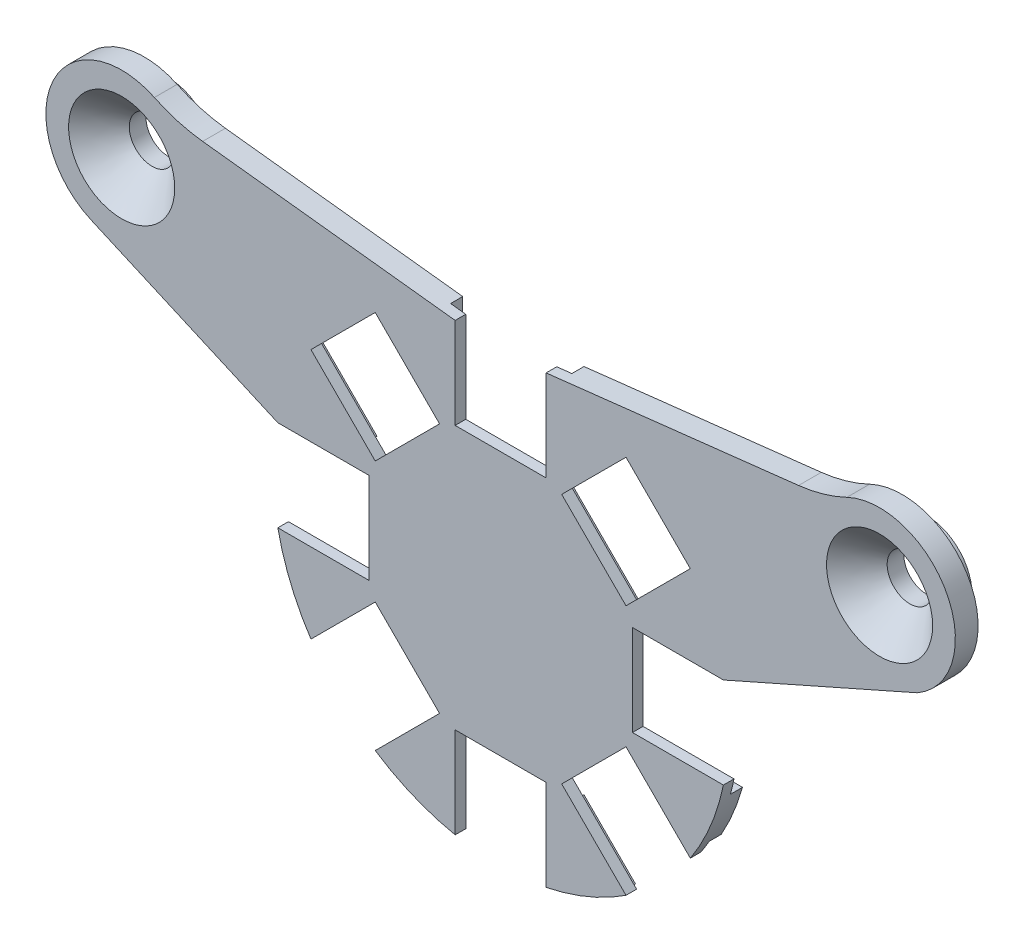
from build123d import *

# Parameters (mm, degrees)
SKETCH_1_R          = 1.5
EXTRUDE_1_DEPTH     = 1.5
CUT_EXTRUDE_2_DEPTH = 0.8
SKETCH_4_R          = 3
SKETCH_4_R_2        = 1.5
EXTRUDE_2_DEPTH     = 1.6
FILLET_1_R          = 1
CHAMFER_1_SIZE      = 2


with BuildPart() as part:
    # Эскиз1 → Бобышка-Вытянуть1 (new body)
    with BuildSketch(Plane.XY):
        with BuildLine():
            Line((-3, 14.696938457), (-3, 8.696938457))
            Line((-3, 8.696938457), (3, 8.696938457))
            Line((3, 8.696938457), (3, 14.696938457))
            Line((3, 14.696938457), (19.657078674, 16.594796577))
            ThreePointArc((19.657078674, 16.594796577), (21.287556094, 16.919662188), (22.841677521, 17.51017118))
            ThreePointArc((22.841677521, 17.51017118), (29.425159504, 15.327651899), (27.493638863, 8.666206601))
            Line((27.493638863, 8.666206601), (14.696938457, 3))
            Line((14.696938457, 3), (8.696938457, 3))
            Line((8.696938457, 3), (8.696938457, -3))
            Line((8.696938457, -3), (14.696938457, -3))
            ThreePointArc((14.696938457, -3), (13.858192988, -5.740251485), (12.513625189, -8.270984502))
            Line((12.513625189, -8.270984502), (8.270984502, -4.028343815))
            Line((8.270984502, -4.028343815), (4.028343815, -8.270984502))
            Line((4.028343815, -8.270984502), (8.270984502, -12.513625189))
            ThreePointArc((8.270984502, -12.513625189), (5.740251485, -13.858192988), (3, -14.696938457))
            Line((3, -14.696938457), (3, -8.696938457))
            Line((3, -8.696938457), (-3, -8.696938457))
            Line((-3, -8.696938457), (-3, -14.696938457))
            ThreePointArc((-3, -14.696938457), (-5.740251485, -13.858192988), (-8.270984502, -12.513625189))
            Line((-8.270984502, -12.513625189), (-4.028343815, -8.270984502))
            Line((-4.028343815, -8.270984502), (-8.270984502, -4.028343815))
            Line((-8.270984502, -4.028343815), (-12.513625189, -8.270984502))
            ThreePointArc((-12.513625189, -8.270984502), (-13.858192988, -5.740251485), (-14.696938457, -3))
            Line((-14.696938457, -3), (-8.696938457, -3))
            Line((-8.696938457, -3), (-8.696938457, 3))
            Line((-8.696938457, 3), (-14.696938457, 3))
            Line((-14.696938457, 3), (-27.014954435, 8.423980045))
            ThreePointArc((-27.014954435, 8.423980045), (-29.543661072, 15.086898192), (-22.841677521, 17.51017118))
            ThreePointArc((-22.841677521, 17.51017118), (-21.287556094, 16.919662188), (-19.657078674, 16.594796577))
            Line((-19.657078674, 16.594796577), (-3, 14.696938457))
        make_face()
        with Locations((-25, 13)):
            Circle(SKETCH_1_R, mode=Mode.SUBTRACT)
        with Locations((25, 13)):
            Circle(SKETCH_1_R, mode=Mode.SUBTRACT)
        Polygon((4.028343815, 8.270984502), (8.270984502, 4.028343815), (12.513625189, 8.270984502), (8.270984502, 12.513625189), align=None, mode=Mode.SUBTRACT)
        Polygon((-8.270984502, 4.028343815), (-4.028343815, 8.270984502), (-8.270984502, 12.513625189), (-12.513625189, 8.270984502), align=None, mode=Mode.SUBTRACT)
    extrude(amount=EXTRUDE_1_DEPTH)

    # Эскиз3 → Вырез-Вытянуть2 (cut)
    with BuildSketch(Plane(origin=(0, 0, 0), x_dir=(-1, 0, 0), z_dir=(0, 0, -1))):
        Polygon((-4, 7.696938457), (-4, 9.656854249), (-7.87527044, 13.53212469), (-13.53212469, 7.87527044), (-9.656854249, 4), (-7.696938457, 4), (-7.696938457, 3.188176298), (-3.188176298, 7.696938457), align=None)
        Polygon((-8.270984502, 4.028343815), (-12.513625189, 8.270984502), (-8.270984502, 12.513625189), (-4.028343815, 8.270984502), align=None, mode=Mode.SUBTRACT)
        Polygon((-2.614130252, 8.270984502), (-4, 9.656854249), (-4, 7.696938457), (-3.188176298, 7.696938457), align=None)
        Polygon((-3, 14.696938457), (-4, 14.81087549), (-4, 9.656854249), (-2.614130252, 8.270984502), (-3.188176298, 7.696938457), (3.188176298, 7.696938457), (2.614130252, 8.270984502), (4, 9.656854249), (4, 14.81087549), (3, 14.696938457), (3, 8.696938457), (-3, 8.696938457), align=None)
        Polygon((4, 7.696938457), (4, 9.656854249), (2.614130252, 8.270984502), (3.188176298, 7.696938457), align=None)
        Polygon((7.87527044, 13.53212469), (4, 9.656854249), (4, 7.696938457), (3.188176298, 7.696938457), (7.696938457, 3.188176298), (7.696938457, 4), (9.656854249, 4), (13.53212469, 7.87527044), align=None)
        Polygon((4.028343815, 8.270984502), (8.270984502, 12.513625189), (12.513625189, 8.270984502), (8.270984502, 4.028343815), align=None, mode=Mode.SUBTRACT)
        Polygon((7.696938457, 4), (7.696938457, 3.188176298), (8.270984502, 2.614130252), (9.656854249, 4), align=None)
        with BuildLine():
            Line((8.270984502, 2.614130252), (7.696938457, 3.188176298))
            Line((7.696938457, 3.188176298), (7.696938457, -3.188176298))
            Line((7.696938457, -3.188176298), (8.270984502, -2.614130252))
            Line((8.270984502, -2.614130252), (9.656854249, -4))
            Line((9.656854249, -4), (14.456832295, -4))
            ThreePointArc((14.456832295, -4), (14.585458075, -3.502058358), (14.696938457, -3))
            Line((14.696938457, -3), (8.696938457, -3))
            Line((8.696938457, -3), (8.696938457, 3))
            Line((8.696938457, 3), (14.696938457, 3))
            Line((14.696938457, 3), (15.137314264, 3.193910253))
            Line((15.137314264, 3.193910253), (15.137314264, 4))
            Line((15.137314264, 4), (9.656854249, 4))
            Line((9.656854249, 4), (8.270984502, 2.614130252))
        make_face()
        Polygon((8.270984502, -2.614130252), (7.696938457, -3.188176298), (7.696938457, -4), (9.656854249, -4), align=None)
        with BuildLine():
            Line((7.696938457, -4), (7.696938457, -3.188176298))
            Line((7.696938457, -3.188176298), (3.188176298, -7.696938457))
            Line((3.188176298, -7.696938457), (4, -7.696938457))
            Line((4, -7.696938457), (4, -9.656854249))
            Line((4, -9.656854249), (7.394097025, -13.050951275))
            ThreePointArc((7.394097025, -13.050951275), (7.837147099, -12.789805525), (8.270984502, -12.513625189))
            Line((8.270984502, -12.513625189), (4.028343815, -8.270984502))
            Line((4.028343815, -8.270984502), (8.270984502, -4.028343815))
            Line((8.270984502, -4.028343815), (12.513625189, -8.270984502))
            ThreePointArc((12.513625189, -8.270984502), (12.789805525, -7.837147099), (13.050951275, -7.394097025))
            Line((13.050951275, -7.394097025), (9.656854249, -4))
            Line((9.656854249, -4), (7.696938457, -4))
        make_face()
        with BuildLine():
            Line((3.188176298, -7.696938457), (-3.188176298, -7.696938457))
            Line((-3.188176298, -7.696938457), (-2.614130252, -8.270984502))
            Line((-2.614130252, -8.270984502), (-4, -9.656854249))
            Line((-4, -9.656854249), (-4, -14.456832295))
            ThreePointArc((-4, -14.456832295), (-3.502058358, -14.585458075), (-3, -14.696938457))
            Line((-3, -14.696938457), (-3, -8.696938457))
            Line((-3, -8.696938457), (3, -8.696938457))
            Line((3, -8.696938457), (3, -14.696938457))
            ThreePointArc((3, -14.696938457), (3.502058358, -14.585458075), (4, -14.456832295))
            Line((4, -14.456832295), (4, -9.656854249))
            Line((4, -9.656854249), (2.614130252, -8.270984502))
            Line((2.614130252, -8.270984502), (3.188176298, -7.696938457))
        make_face()
        Polygon((4, -7.696938457), (3.188176298, -7.696938457), (2.614130252, -8.270984502), (4, -9.656854249), align=None)
        Polygon((-2.614130252, -8.270984502), (-3.188176298, -7.696938457), (-4, -7.696938457), (-4, -9.656854249), align=None)
        with BuildLine():
            Line((-3.188176298, -7.696938457), (-7.696938457, -3.188176298))
            Line((-7.696938457, -3.188176298), (-7.696938457, -4))
            Line((-7.696938457, -4), (-9.656854249, -4))
            Line((-9.656854249, -4), (-13.050951275, -7.394097025))
            ThreePointArc((-13.050951275, -7.394097025), (-12.789805525, -7.837147099), (-12.513625189, -8.270984502))
            Line((-12.513625189, -8.270984502), (-8.270984502, -4.028343815))
            Line((-8.270984502, -4.028343815), (-4.028343815, -8.270984502))
            Line((-4.028343815, -8.270984502), (-8.270984502, -12.513625189))
            ThreePointArc((-8.270984502, -12.513625189), (-7.837147099, -12.789805525), (-7.394097025, -13.050951275))
            Line((-7.394097025, -13.050951275), (-4, -9.656854249))
            Line((-4, -9.656854249), (-4, -7.696938457))
            Line((-4, -7.696938457), (-3.188176298, -7.696938457))
        make_face()
        Polygon((-7.696938457, -4), (-7.696938457, -3.188176298), (-8.270984502, -2.614130252), (-9.656854249, -4), align=None)
        with BuildLine():
            Line((-7.696938457, -3.188176298), (-7.696938457, 3.188176298))
            Line((-7.696938457, 3.188176298), (-8.270984502, 2.614130252))
            Line((-8.270984502, 2.614130252), (-9.656854249, 4))
            Line((-9.656854249, 4), (-15.137314264, 4))
            Line((-15.137314264, 4), (-15.137314264, 3.194992477))
            Line((-15.137314264, 3.194992477), (-14.696938457, 3))
            Line((-14.696938457, 3), (-8.696938457, 3))
            Line((-8.696938457, 3), (-8.696938457, -3))
            Line((-8.696938457, -3), (-14.696938457, -3))
            ThreePointArc((-14.696938457, -3), (-14.585458075, -3.502058358), (-14.456832295, -4))
            Line((-14.456832295, -4), (-9.656854249, -4))
            Line((-9.656854249, -4), (-8.270984502, -2.614130252))
            Line((-8.270984502, -2.614130252), (-7.696938457, -3.188176298))
        make_face()
        Polygon((-8.270984502, 2.614130252), (-7.696938457, 3.188176298), (-7.696938457, 4), (-9.656854249, 4), align=None)
    extrude(amount=-CUT_EXTRUDE_2_DEPTH, mode=Mode.SUBTRACT)

    # Эскиз4 → Бобышка-Вытянуть2 (add)
    with BuildSketch(Plane(origin=(0, 0, 0), x_dir=(-1, 0, 0), z_dir=(0, 0, -1))):
        with Locations((25, 13)):
            Circle(SKETCH_4_R)
        with Locations((25, 13)):
            Circle(SKETCH_4_R_2, mode=Mode.SUBTRACT)
        with Locations((-25, 13)):
            Circle(SKETCH_4_R)
        with Locations((-25, 13)):
            Circle(SKETCH_4_R_2, mode=Mode.SUBTRACT)
    extrude(amount=EXTRUDE_2_DEPTH)

    # Скругление1
    fillet_1_edges = [part.edges().sort_by_distance(p)[0] for p in [
        (-22, 13, 0),
        (28, 13, 0),
    ]]
    fillet(fillet_1_edges, radius=FILLET_1_R)

    # Фаска1
    chamfer_1_edges = [part.edges().sort_by_distance(p)[0] for p in [
        (-26.5, 13, 1.5),
        (23.5, 13, 1.5),
    ]]
    chamfer(chamfer_1_edges, length=CHAMFER_1_SIZE)


solid = part.part
